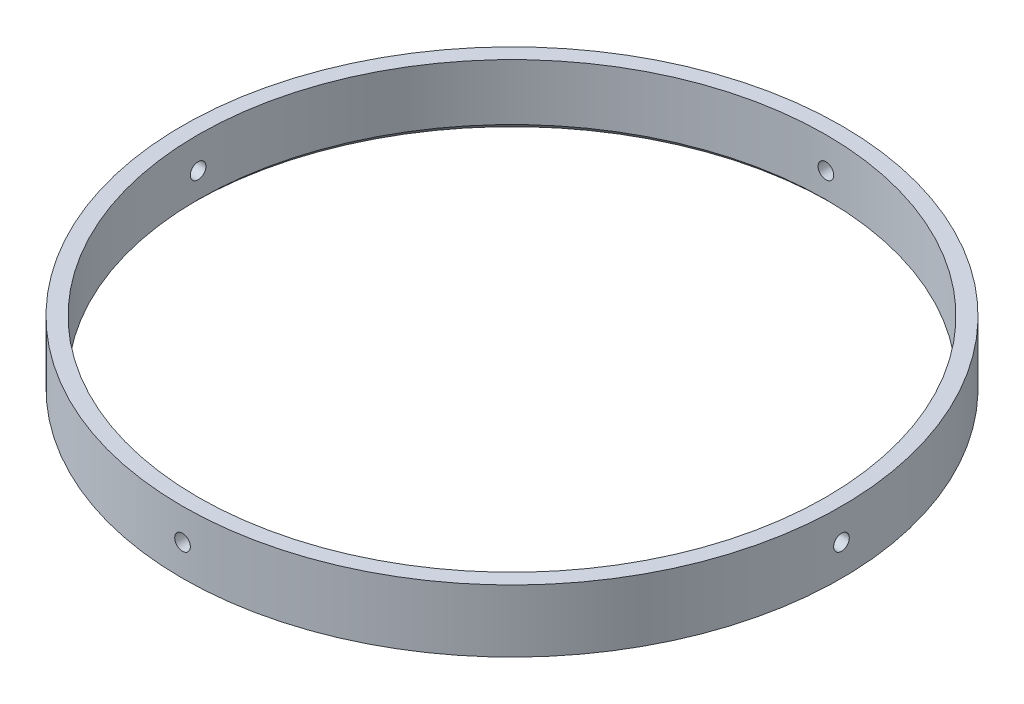
from build123d import *

# Parameters (mm, degrees)
SKETCH1_R           = 66.9925
SKETCH1_R_2         = 63.8175
BOSS_EXTRUDE1_DEPTH = 12.7
CUT_EXTRUDE1_START  = -66.9925
SKETCH2_R           = 1.5875
CUT_EXTRUDE1_DEPTH  = 3.194748
CIRPATTERN1_COUNT   = 4
CHAMFER1_SIZE       = 1.27


with BuildPart() as part:
    # Sketch1 → Boss-Extrude1 (new body)
    with BuildSketch(Plane(origin=(0, 0, 0), x_dir=(1, 0, 0), z_dir=(0, 1, 0))):
        Circle(SKETCH1_R)
        Circle(SKETCH1_R_2, mode=Mode.SUBTRACT)
    extrude(amount=BOSS_EXTRUDE1_DEPTH)

    # Sketch2 → Cut-Extrude1 (cut)
    with BuildSketch(Plane.XY.offset(CUT_EXTRUDE1_START)):
        with Locations((0, 6.35)):
            Circle(SKETCH2_R)
    cut_extrude1 = extrude(amount=CUT_EXTRUDE1_DEPTH, mode=Mode.SUBTRACT)

    # CirPattern1: Cut-Extrude1 ×4 about axis
    cirpattern1_axis = Axis((0, 12.7, 0), (0, -1, 0))
    for i in range(1, CIRPATTERN1_COUNT):
        add(cut_extrude1.rotate(cirpattern1_axis, i * 360 / CIRPATTERN1_COUNT), mode=Mode.SUBTRACT)

    # Chamfer1
    chamfer1_edges = [part.edges().sort_by_distance(p)[0] for p in [
        (-63.8175, 0, 0),
    ]]
    chamfer(chamfer1_edges, length=CHAMFER1_SIZE)


solid = part.part
